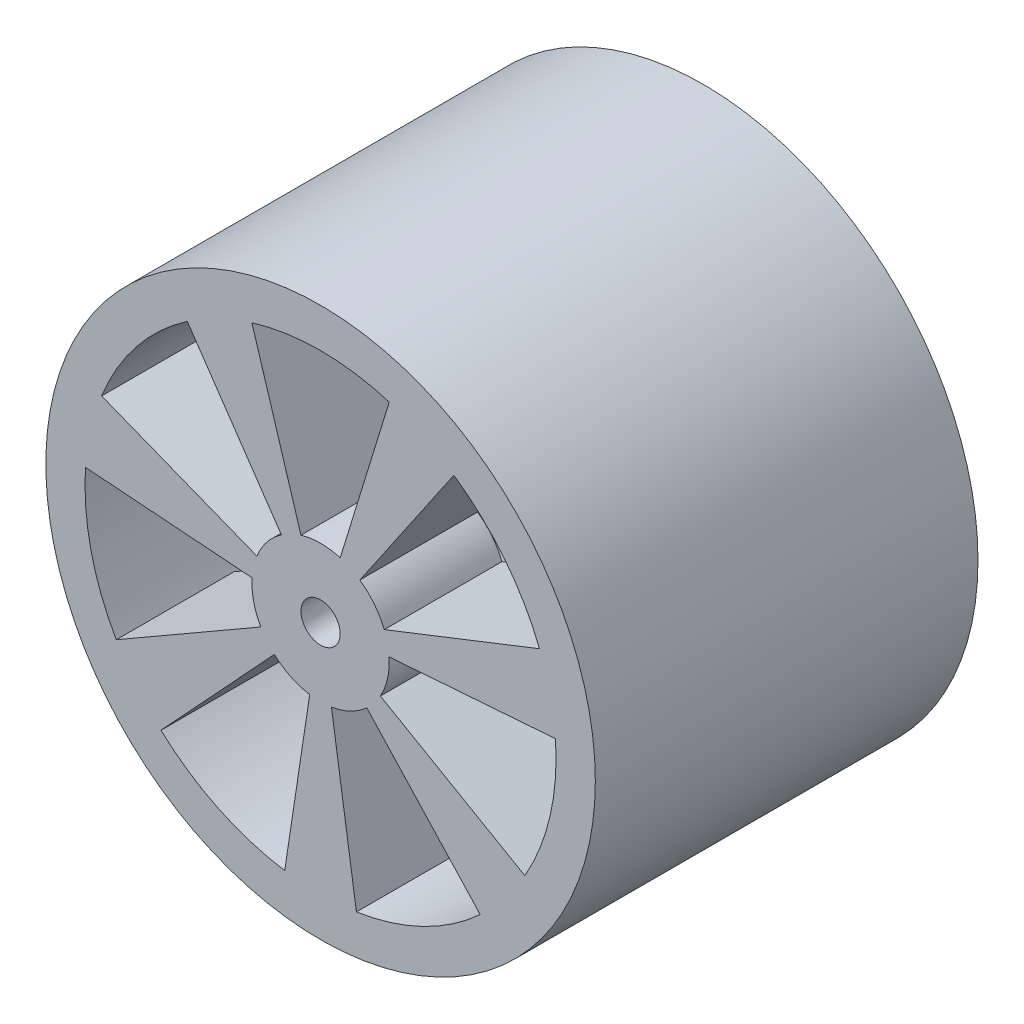
from build123d import *
from build123d.topology import SkipClean

# Parameters (mm, degrees)
SKETCH1_R           = 28
SKETCH1_R_2         = 2
BOSS_EXTRUDE1_DEPTH = 39
SKETCH2_R           = 24
CUT_EXTRUDE1_DEPTH  = 27
CUT_EXTRUDE2_DEPTH  = 4
CUT_EXTRUDE4_DEPTH  = 56.578772926


with BuildPart() as part:
    # Sketch1 → Boss-Extrude1 (new body)
    with BuildSketch(Plane.XY):
        Circle(SKETCH1_R)
        Circle(SKETCH1_R_2, mode=Mode.SUBTRACT)
    extrude(amount=BOSS_EXTRUDE1_DEPTH)

    # Sketch2 → Cut-Extrude1 (cut)
    with BuildSketch(Plane(origin=(0, 0, 0), x_dir=(-1, 0, 0), z_dir=(0, 0, -1))):
        Circle(SKETCH2_R)
    extrude(amount=-CUT_EXTRUDE1_DEPTH, mode=Mode.SUBTRACT)

    # Sketch3 → Cut-Extrude2 (cut)
    with BuildSketch(Plane(origin=(0, 0, 27), x_dir=(-1, 0, 0), z_dir=(0, 0, -1))):
        Polygon((6, 0), (3, 5.196152423), (-3, 5.196152423), (-6, 0), (-3, -5.196152423), (3, -5.196152423), align=None)
    extrude(amount=-CUT_EXTRUDE2_DEPTH, mode=Mode.SUBTRACT)

    # Sketch5 → Cut-Extrude4 (cut, through all)
    with SkipClean():  # the faces are left unmerged after this step: merging them gives an invalid solid
        with BuildSketch(Plane.XY.offset(39)):
            with BuildLine():
                Line((-7, 22.956480566), (-2, 6.708203932))
                ThreePointArc((-2, 6.708203932), (0, 7), (2, 6.708203932))
                Line((2, 6.708203932), (7, 22.956480566))
                ThreePointArc((7, 22.956480566), (0, 24), (-7, 22.956480566))
            make_face()
            with BuildLine():
                Line((13.583670621, 19.785951897), (3.997705422, 5.746159706))
                ThreePointArc((3.997705422, 5.746159706), (5.472820377, 4.364428613), (6.491664629, 2.618833776))
                Line((6.491664629, 2.618833776), (22.312527847, 8.840311143))
                ThreePointArc((22.312527847, 8.840311143), (18.763955579, 14.963755245), (13.583670621, 19.785951897))
            make_face()
            with BuildLine():
                Line((23.938560207, 1.716197889), (6.985057122, 0.45714002))
                ThreePointArc((6.985057122, 0.45714002), (6.824495385, -1.557646538), (6.094973386, -3.442571629))
                Line((6.094973386, -3.442571629), (20.823267132, -11.932792881))
                ThreePointArc((20.823267132, -11.932792881), (23.398269892, -5.340502415), (23.938560207, 1.716197889))
            make_face()
            with BuildLine():
                Line((16.2672257, -17.645888133), (4.712518341, -5.176115424))
                ThreePointArc((4.712518341, -5.176115424), (3.037186174, -6.306782075), (1.108642869, -6.911650381))
                Line((1.108642869, -6.911650381), (3.65366155, -23.720260481))
                ThreePointArc((3.65366155, -23.720260481), (10.413209739, -21.62325283), (16.2672257, -17.645888133))
            make_face()
            with BuildLine():
                Line((-3.65366155, -23.720260481), (-1.108642869, -6.911650381))
                ThreePointArc((-1.108642869, -6.911650381), (-3.037186174, -6.306782075), (-4.712518341, -5.176115424))
                Line((-4.712518341, -5.176115424), (-16.2672257, -17.645888133))
                ThreePointArc((-16.2672257, -17.645888133), (-10.413209739, -21.62325283), (-3.65366155, -23.720260481))
            make_face()
            with BuildLine():
                Line((-20.823267132, -11.932792881), (-6.094973386, -3.442571629))
                ThreePointArc((-6.094973386, -3.442571629), (-6.824495385, -1.557646538), (-6.985057122, 0.45714002))
                Line((-6.985057122, 0.45714002), (-23.938560207, 1.716197889))
                ThreePointArc((-23.938560207, 1.716197889), (-23.398269892, -5.340502415), (-20.823267132, -11.932792881))
            make_face()
            with BuildLine():
                Line((-22.312527847, 8.840311143), (-6.491664629, 2.618833776))
                ThreePointArc((-6.491664629, 2.618833776), (-5.472820377, 4.364428613), (-3.997705422, 5.746159706))
                Line((-3.997705422, 5.746159706), (-13.583670621, 19.785951897))
                ThreePointArc((-13.583670621, 19.785951897), (-18.763955579, 14.963755245), (-22.312527847, 8.840311143))
            make_face()
        extrude(amount=-CUT_EXTRUDE4_DEPTH, mode=Mode.SUBTRACT)


solid = part.part
